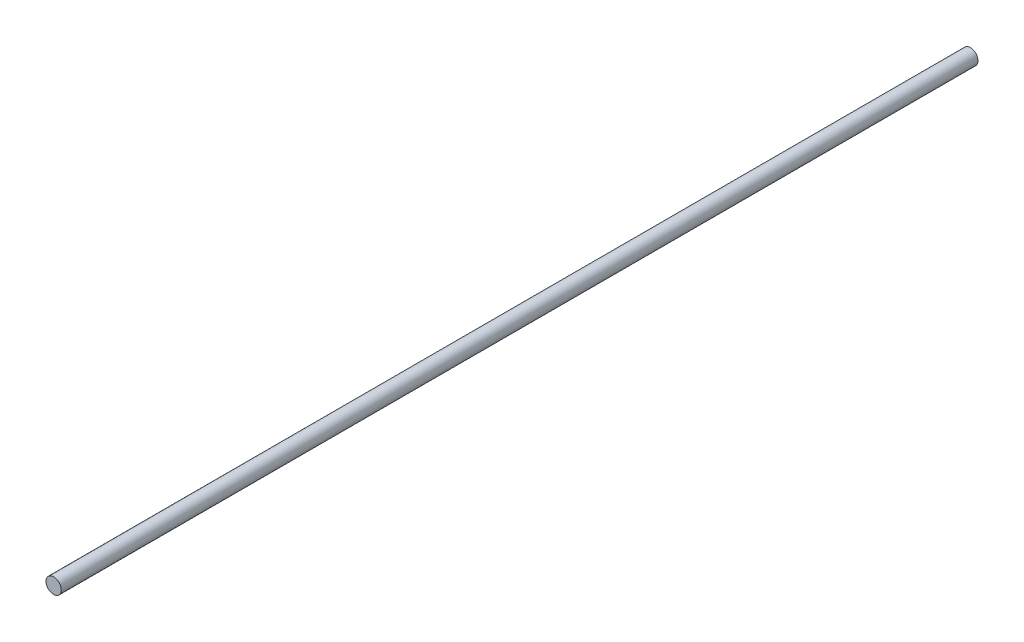
from build123d import *

# Parameters (mm, degrees)
SKETCH1_R           = 6.35
BOSS_EXTRUDE1_DEPTH = 381


with BuildPart() as part:
    # Sketch1 → Boss-Extrude1 (new body, symmetric)
    with BuildSketch(Plane.XY):
        Circle(SKETCH1_R)
    extrude(amount=BOSS_EXTRUDE1_DEPTH, both=True)


solid = part.part
